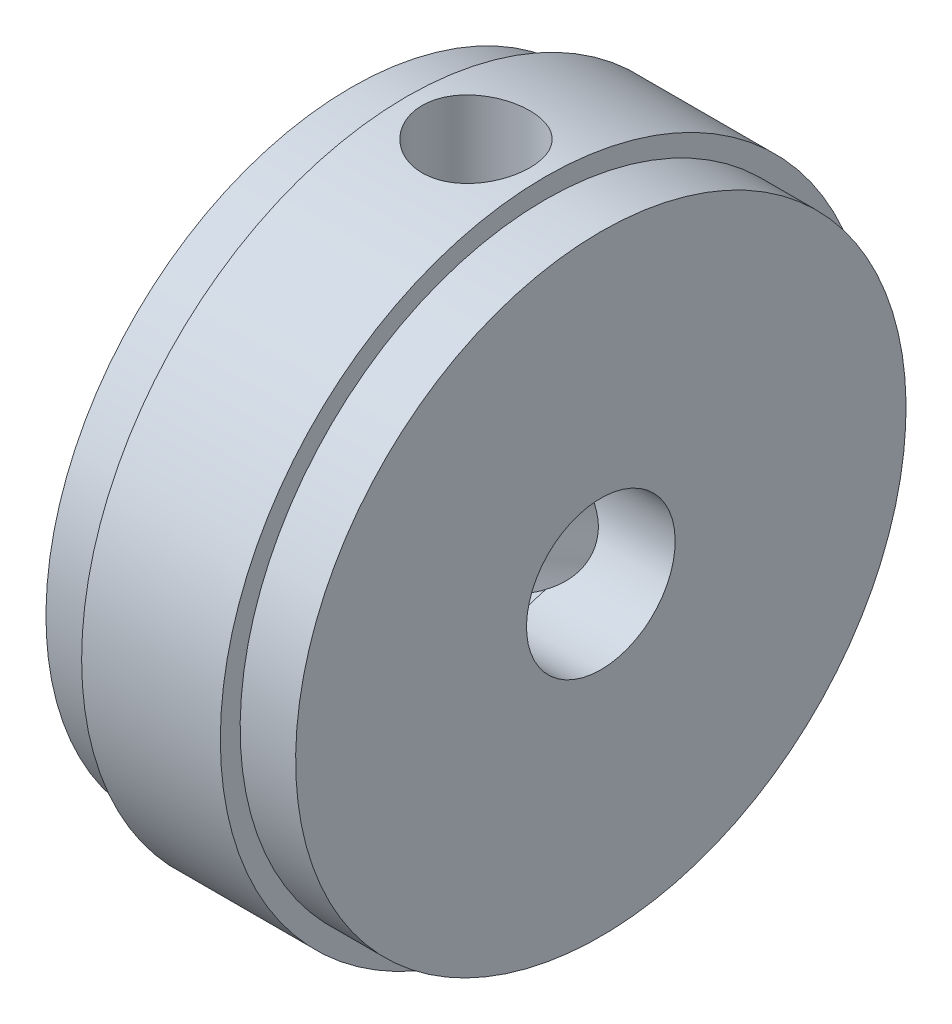
from build123d import *

# Parameters (mm, degrees)
SKETCH2_R          = 2.38125
CUT_EXTRUDE1_DEPTH = 9
CIRPATTERN1_COUNT  = 2
CIRPATTERN1_ANGLE  = 120


with BuildPart() as part:
    # Sketch1 → Revolve1 (revolve)
    with BuildSketch(Plane.XY):
        Polygon((4, 0), (-4, 0), (-4, 9.779), (-2.222, 9.779), (-2.222, 10.414), (2.222, 10.414), (2.222, 9.779), (4, 9.779), align=None)
    revolve(axis=Axis((8.430806561, 0, 0), (-1, 0, 0)))

    # Sketch2 → Cut-Extrude1 (cut, through all)
    with BuildSketch(Plane.ZY.offset(4)):
        Circle(SKETCH2_R)
    extrude(amount=-CUT_EXTRUDE1_DEPTH, mode=Mode.SUBTRACT)

    # Sketch4 → #8-32 Tapped Hole1 (revolve, cut)
    with BuildSketch(Plane(origin=(0, 10.414, 0), x_dir=(0, 0, 1), z_dir=(1, 0, 0))):
        Polygon((0, 0), (0, 13.483806461), (1.7272, 12.446), (1.7272, 0), align=None)
    f_8_32_tapped_hole1 = revolve(axis=Axis((0, 16.764, 0), (0, -1, 0)), mode=Mode.SUBTRACT)

    # CirPattern1: #8-32 Tapped Hole1 ×2 about axis
    cirpattern1_axis = Axis((4, 0, 0), (-1, 0, 0))
    for i in range(1, CIRPATTERN1_COUNT):
        add(f_8_32_tapped_hole1.rotate(cirpattern1_axis, i * CIRPATTERN1_ANGLE / (CIRPATTERN1_COUNT - 1)), mode=Mode.SUBTRACT)


solid = part.part
